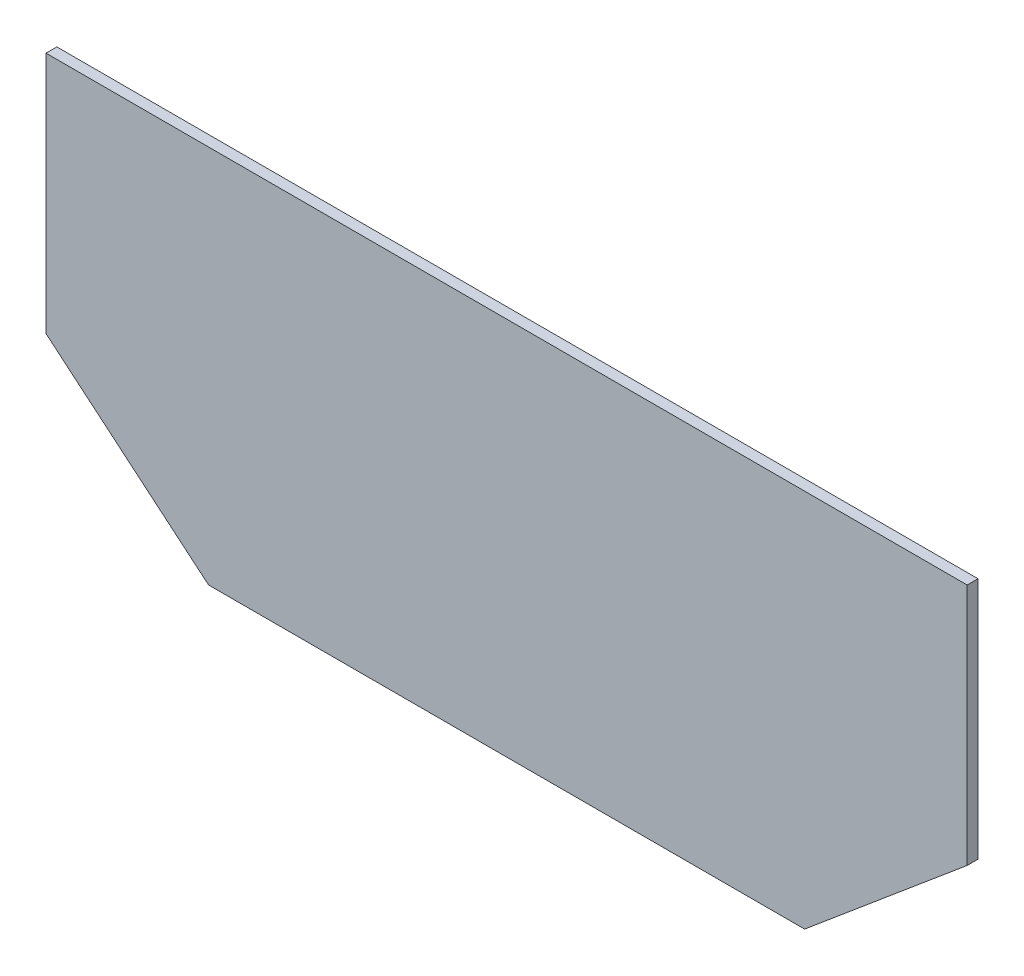
from build123d import *

# Parameters (mm, degrees)
RESSALTO_EXTRUS_O1_DEPTH = 2


with BuildPart() as part:
    # Esboço1 → Ressalto-extrusão1 (new body)
    with BuildSketch(Plane.XY):
        Polygon((55, 0), (-55, 0), (-85, 25.172988935), (-85, 70), (85, 70), (85, 25.172988935), align=None)
    extrude(amount=RESSALTO_EXTRUS_O1_DEPTH)


solid = part.part
